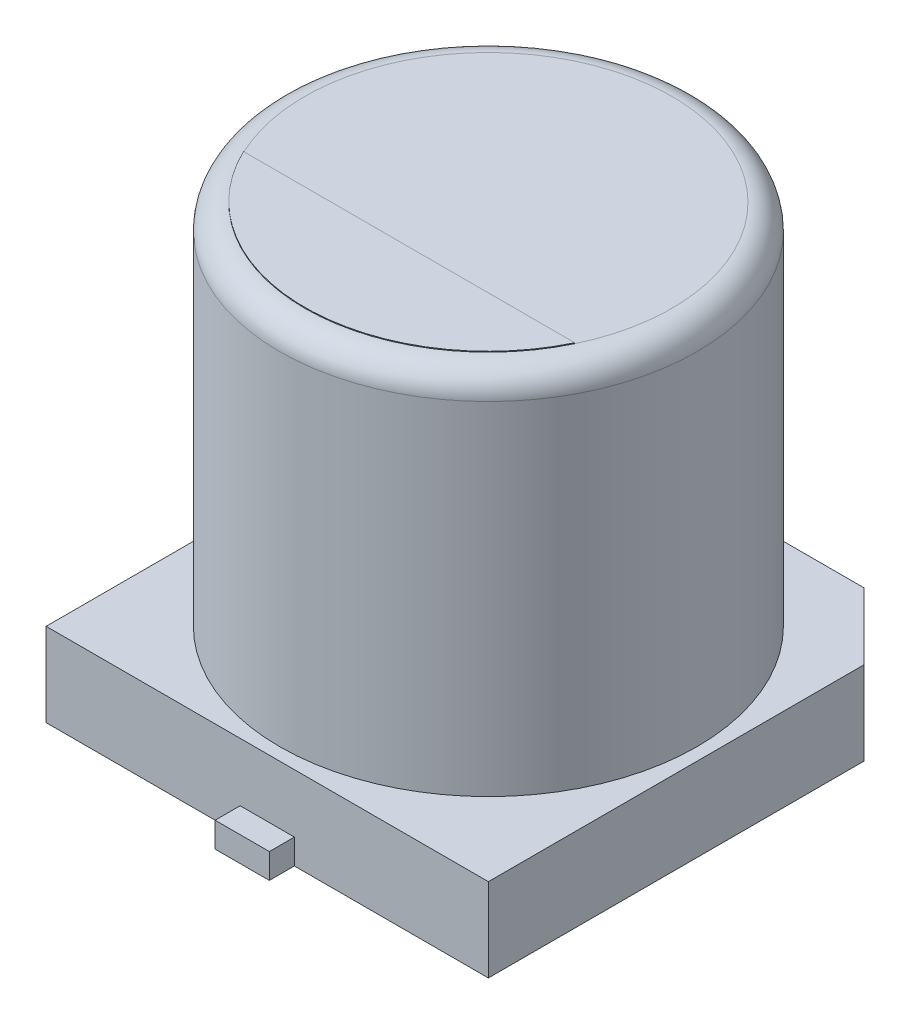
from build123d import *

# Parameters (mm, degrees)
BOSS_EXTRUDE1_DEPTH = 1
SKETCH3_R           = 2.5
BOSS_EXTRUDE2_DEPTH = 5.4
FILLET1_R           = 0.3
SKETCH4_W           = 0.65
SKETCH4_H           = 2.2
BOSS_EXTRUDE3_DEPTH = 0.3
BOSS_EXTRUDE4_DEPTH = 0.01


with BuildPart() as part:
    # Sketch2 → Boss-Extrude1 (new body)
    with BuildSketch(Plane(origin=(0, 0, 0), x_dir=(1, 0, 0), z_dir=(0, 1, 0))):
        Polygon((2.65, -2.65), (-2.65, -2.65), (-2.65, 1.85), (-1.85, 2.65), (1.85, 2.65), (2.65, 1.85), align=None)
    extrude(amount=BOSS_EXTRUDE1_DEPTH)

    # Sketch3 → Boss-Extrude2 (add)
    with BuildSketch(Plane(origin=(0, 0, 0), x_dir=(1, 0, 0), z_dir=(0, 1, 0))):
        Circle(SKETCH3_R)
    extrude(amount=BOSS_EXTRUDE2_DEPTH)

    # Fillet1
    fillet1_edges = [part.edges().sort_by_distance(p)[0] for p in [
        (-2.5, 5.4, 0),
    ]]
    fillet(fillet1_edges, radius=FILLET1_R)

    # Sketch4 → Boss-Extrude3 (add)
    with BuildSketch(Plane(origin=(0, 0, 0), x_dir=(1, 0, 0), z_dir=(0, 1, 0))):
        with Locations((0, 1.85)):
            Rectangle(SKETCH4_W, SKETCH4_H)
        with Locations((0, -1.85)):
            Rectangle(SKETCH4_W, SKETCH4_H)
    extrude(amount=BOSS_EXTRUDE3_DEPTH)

    # Sketch5 → Boss-Extrude4 (add)
    with BuildSketch(Plane(origin=(0, 5.4, 0), x_dir=(1, 0, 0), z_dir=(0, 1, 0))):
        with BuildLine():
            Line((-1.984482533, -0.949646816), (1.984482533, -0.949646816))
            ThreePointArc((1.984482533, -0.949646816), (0, -2.2), (-1.984482533, -0.949646816))
        make_face()
    extrude(amount=BOSS_EXTRUDE4_DEPTH)


solid = part.part
